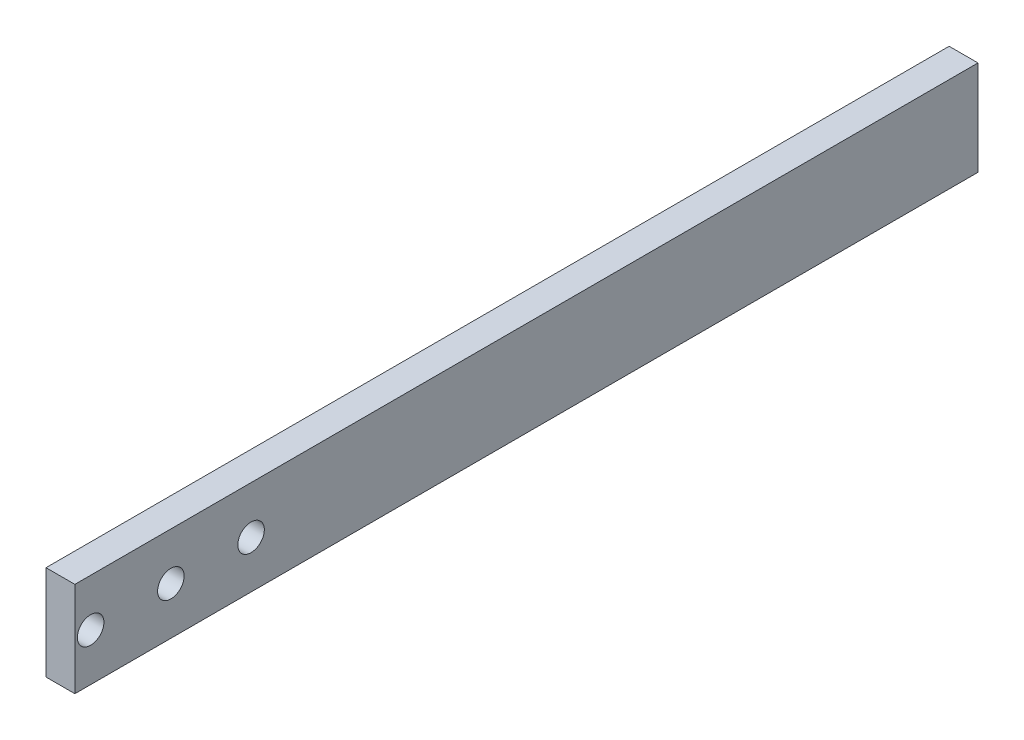
from build123d import *

# Parameters (mm, degrees)
SKETCH1_W           = 4.57
SKETCH1_H           = 143
BOSS_EXTRUDE1_DEPTH = 18
SKETCH2_R           = 2.1
CUT_EXTRUDE1_DEPTH  = 18
SKETCH3_W           = 145
SKETCH3_H           = 3
CUT_EXTRUDE2_DEPTH  = 10


with BuildPart() as part:
    # Sketch1 → Boss-Extrude1 (new body)
    with BuildSketch(Plane(origin=(0, 0, 0), x_dir=(1, 0, 0), z_dir=(0, 1, 0))):
        with Locations((-47.715, 196.5)):
            Rectangle(SKETCH1_W, SKETCH1_H)
    extrude(amount=BOSS_EXTRUDE1_DEPTH)

    # Sketch2 → Cut-Extrude1 (cut)
    with BuildSketch(Plane.ZY.offset(50)):
        with Locations((-127.5, 10.5)):
            Circle(SKETCH2_R)
        with Locations((-140.2, 10.5)):
            Circle(SKETCH2_R)
        with Locations((-152.9, 10.5)):
            Circle(SKETCH2_R)
    extrude(amount=-CUT_EXTRUDE1_DEPTH, mode=Mode.SUBTRACT)

    # Sketch3 → Cut-Extrude2 (cut)
    with BuildSketch(Plane.ZY.offset(50)):
        with Locations((-197.5, 1.5)):
            Rectangle(SKETCH3_W, SKETCH3_H)
    extrude(amount=-CUT_EXTRUDE2_DEPTH, mode=Mode.SUBTRACT)


solid = part.part
